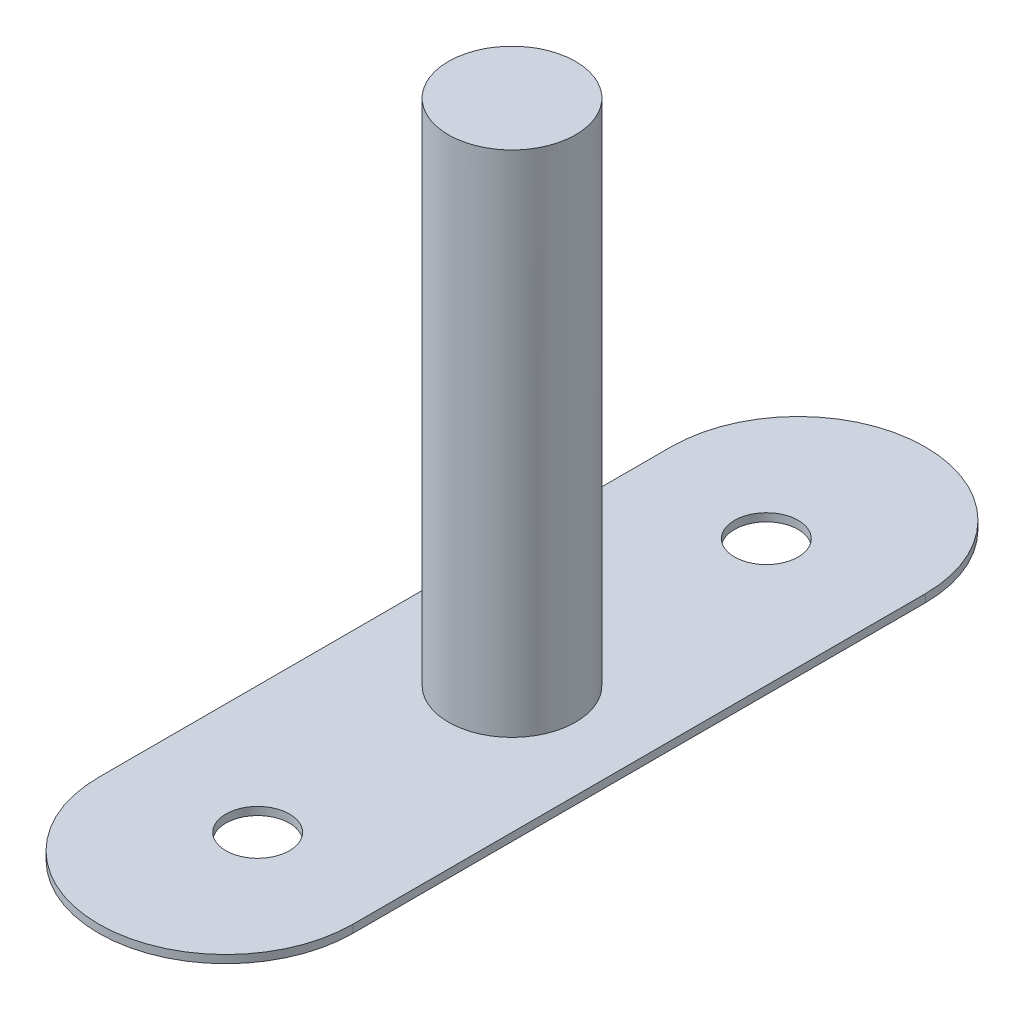
from build123d import *

# Parameters (mm, degrees)
BOSS_EXTRUDE1_DEPTH                            = 0.79375
CBORE_FOR_4_BUTTON_HEAD_CAP_SCREW1_D           = 3.2639
CBORE_FOR_4_BUTTON_HEAD_CAP_SCREW1_CBORE_D     = 6.35
CBORE_FOR_4_BUTTON_HEAD_CAP_SCREW1_CBORE_DEPTH = 1.4986
SKETCH6_R                                      = 6.35
BOSS_EXTRUDE2_DEPTH                            = 50.8


with BuildPart() as part:
    # Sketch1 → Boss-Extrude1 (new body)
    with BuildSketch(Plane(origin=(0, 0, 0), x_dir=(1, 0, 0), z_dir=(0, 1, 0))):
        with BuildLine():
            Line((-12.7, -28.575), (-12.7, 28.575))
            ThreePointArc((-12.7, 28.575), (0, 41.275), (12.7, 28.575))
            Line((12.7, 28.575), (12.7, -28.575))
            ThreePointArc((12.7, -28.575), (0, -41.275), (-12.7, -28.575))
        make_face()
    extrude(amount=BOSS_EXTRUDE1_DEPTH)

    # CBORE for #4 Button Head Cap Screw1 (through all)
    with Locations(Plane(origin=(0, 0.79375, 0), x_dir=(-1, 0, 0), z_dir=(0, 1, 0))):
        with Locations((0, 25.4), (0, -25.4)):
            CounterBoreHole(CBORE_FOR_4_BUTTON_HEAD_CAP_SCREW1_D / 2, CBORE_FOR_4_BUTTON_HEAD_CAP_SCREW1_CBORE_D / 2, CBORE_FOR_4_BUTTON_HEAD_CAP_SCREW1_CBORE_DEPTH)

    # Sketch6 → Boss-Extrude2 (add)
    with BuildSketch(Plane(origin=(0, 0.79375, 0), x_dir=(1, 0, 0), z_dir=(0, 1, 0))):
        Circle(SKETCH6_R)
    extrude(amount=BOSS_EXTRUDE2_DEPTH)


solid = part.part
